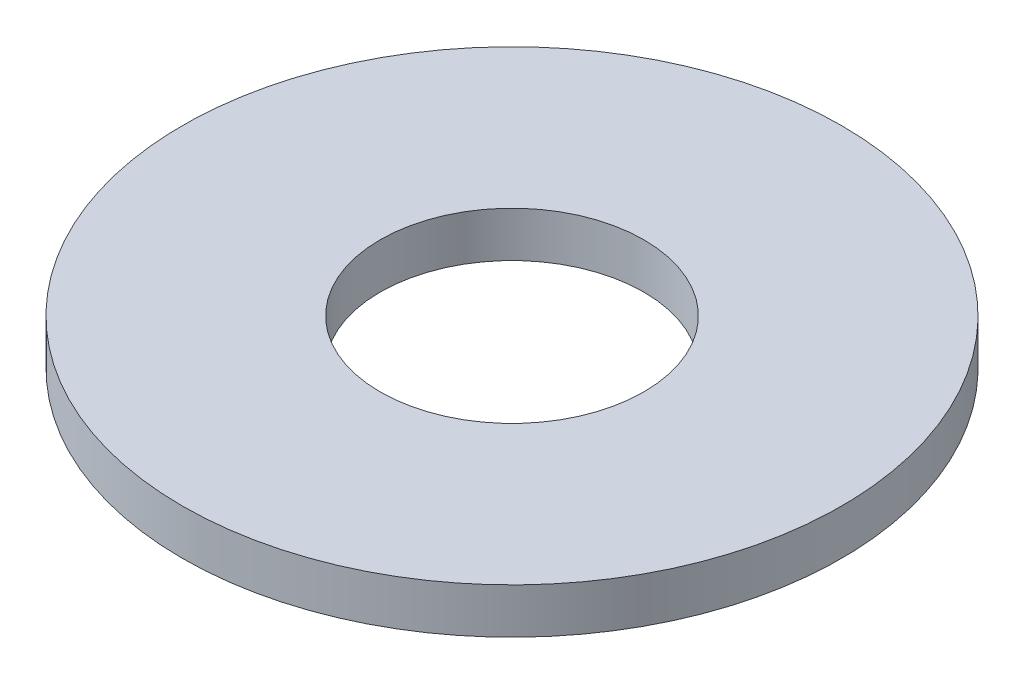
from build123d import *

# Parameters (mm, degrees)
SKETCH1_R           = 7.9375
BOSS_EXTRUDE1_DEPTH = 1.0922
SKETCH5_R           = 3.175
CUT_EXTRUDE1_DEPTH  = 2.0922


with BuildPart() as part:
    # Sketch1 → Boss-Extrude1 (new body)
    with BuildSketch(Plane(origin=(0, 0, 0), x_dir=(1, 0, 0), z_dir=(0, 1, 0))):
        Circle(SKETCH1_R)
    extrude(amount=BOSS_EXTRUDE1_DEPTH)

    # Sketch5 → Cut-Extrude1 (cut, through all)
    with BuildSketch(Plane(origin=(0, 1.0922, 0), x_dir=(-1, 0, 0), z_dir=(0, 1, 0))):
        Circle(SKETCH5_R)
    extrude(amount=-CUT_EXTRUDE1_DEPTH, mode=Mode.SUBTRACT)


solid = part.part
